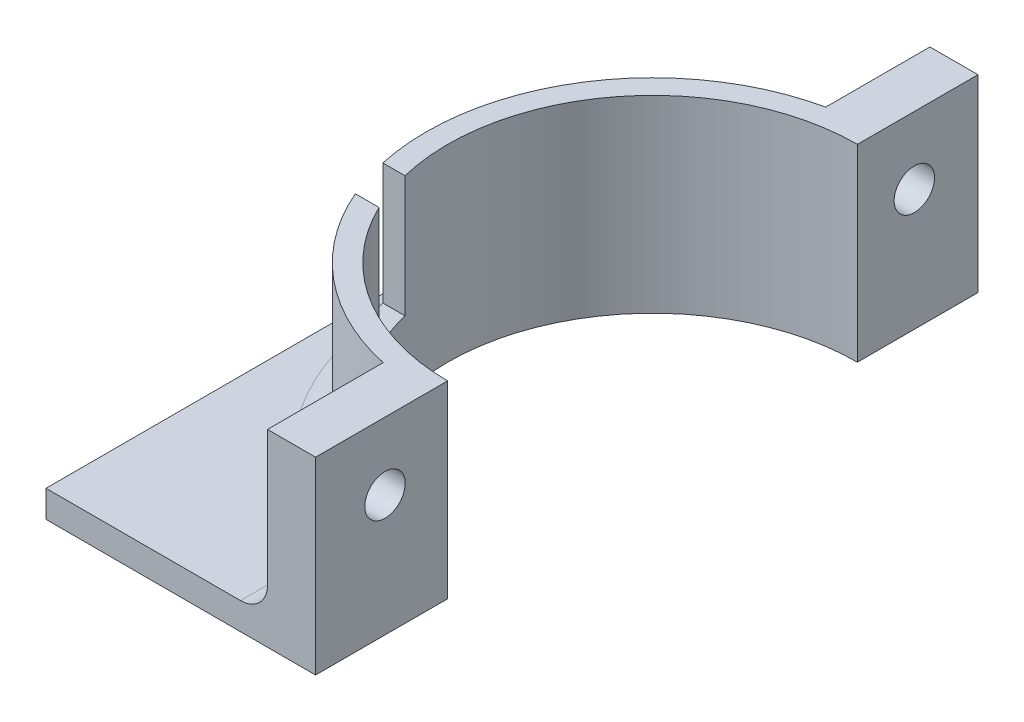
from build123d import *

# Parameters (mm, degrees)
BOSS_EXTRUDE14_DEPTH    = 2.54
BOSS_EXTRUDE15_DEPTH    = 17.78
FILLET3_R               = 2.54
CUT_EXTRUDE3_DEPTH      = 70.692729708
CUT_EXTRUDE3_DEPTH_BACK = 70.692729708
SKETCH5_R               = 1.905
CUT_EXTRUDE4_DEPTH      = 70.692729708
CUT_EXTRUDE4_DEPTH_BACK = 70.692729708
SKETCH6_W               = 3.81
SKETCH6_H               = 11.43


with BuildPart() as part:
    # Sketch3 → Boss-Extrude14 (new body)
    with BuildSketch(Plane(origin=(0, 0, 0), x_dir=(1, 0, 0), z_dir=(0, 1, 0))):
        with BuildLine():
            Line((0, 62.41624918), (0, 0))
            Line((0, 0), (20.870167944, 0))
            Line((20.870167944, 0), (20.870167944, 10.900407257))
            ThreePointArc((20.870167944, 10.900407257), (4.064, 31.75), (20.870167944, 52.599592743))
            Line((20.870167944, 52.599592743), (20.870167944, 62.41624918))
            Line((20.870167944, 62.41624918), (0, 62.41624918))
        make_face()
    extrude(amount=BOSS_EXTRUDE14_DEPTH)

    # Sketch3_18 → Boss-Extrude15 (add)
    with BuildSketch(Plane(origin=(0, 0, 0), x_dir=(1, 0, 0), z_dir=(0, 1, 0))):
        with BuildLine():
            Line((20.870167944, 10.900407257), (20.870167944, 0))
            Line((20.870167944, 0), (25.4, 0))
            Line((25.4, 0), (25.4, 12.446))
            ThreePointArc((25.4, 12.446), (6.096, 31.75), (25.4, 51.054))
            Line((25.4, 51.054), (25.4, 62.41624918))
            Line((25.4, 62.41624918), (20.870167944, 62.41624918))
            Line((20.870167944, 62.41624918), (20.870167944, 52.599592743))
            ThreePointArc((20.870167944, 52.599592743), (4.064, 31.75), (20.870167944, 10.900407257))
        make_face()
    extrude(amount=BOSS_EXTRUDE15_DEPTH)

    # Fillet3
    fillet3_edges = [part.edges().sort_by_distance(p)[0] for p in [
        (20.870167944, 2.54, -57.507920962),
        (4.064, 2.54, -31.75),
        (20.870167944, 2.54, -5.450203629),
    ]]
    fillet(fillet3_edges, radius=FILLET3_R)

    # Sketch5 → Cut-Extrude3 (cut, two sides: drawn at the far end of the back side and taken through both)
    with BuildSketch(Plane(origin=(0, 0, 0), x_dir=(0, 0, -1), z_dir=(1, 0, 0)).offset(-CUT_EXTRUDE3_DEPTH_BACK)):
        with Locations((6.5405, 11.43)):
            Circle(SKETCH5_R)
        with Locations((56.41762459, 11.43)):
            Circle(SKETCH5_R)
    extrude(amount=CUT_EXTRUDE3_DEPTH + CUT_EXTRUDE3_DEPTH_BACK, mode=Mode.SUBTRACT)

    # Sketch6 → Cut-Extrude4 (cut, two sides: drawn at the far end of the back side and taken through both)
    with BuildSketch(Plane(origin=(0, 0, 0), x_dir=(0, 0, -1), z_dir=(1, 0, 0)).offset(-CUT_EXTRUDE4_DEPTH_BACK)):
        with Locations((25.273, 12.065)):
            Rectangle(SKETCH6_W, SKETCH6_H)
    extrude(amount=CUT_EXTRUDE4_DEPTH + CUT_EXTRUDE4_DEPTH_BACK, mode=Mode.SUBTRACT)


solid = part.part
